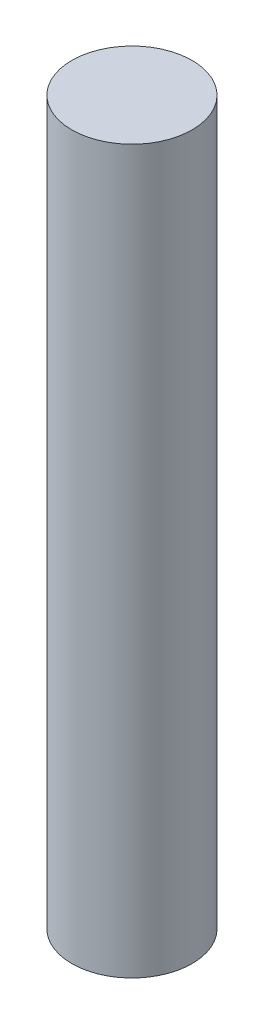
from build123d import *

# Parameters (mm, degrees)
SKETCH2_R           = 2.5
BOSS_EXTRUDE1_DEPTH = 30


with BuildPart() as part:
    # Sketch2 → Boss-Extrude1 (new body)
    with BuildSketch(Plane(origin=(0, 0, 0), x_dir=(1, 0, 0), z_dir=(0, 1, 0))):
        Circle(SKETCH2_R)
    extrude(amount=BOSS_EXTRUDE1_DEPTH)


solid = part.part
